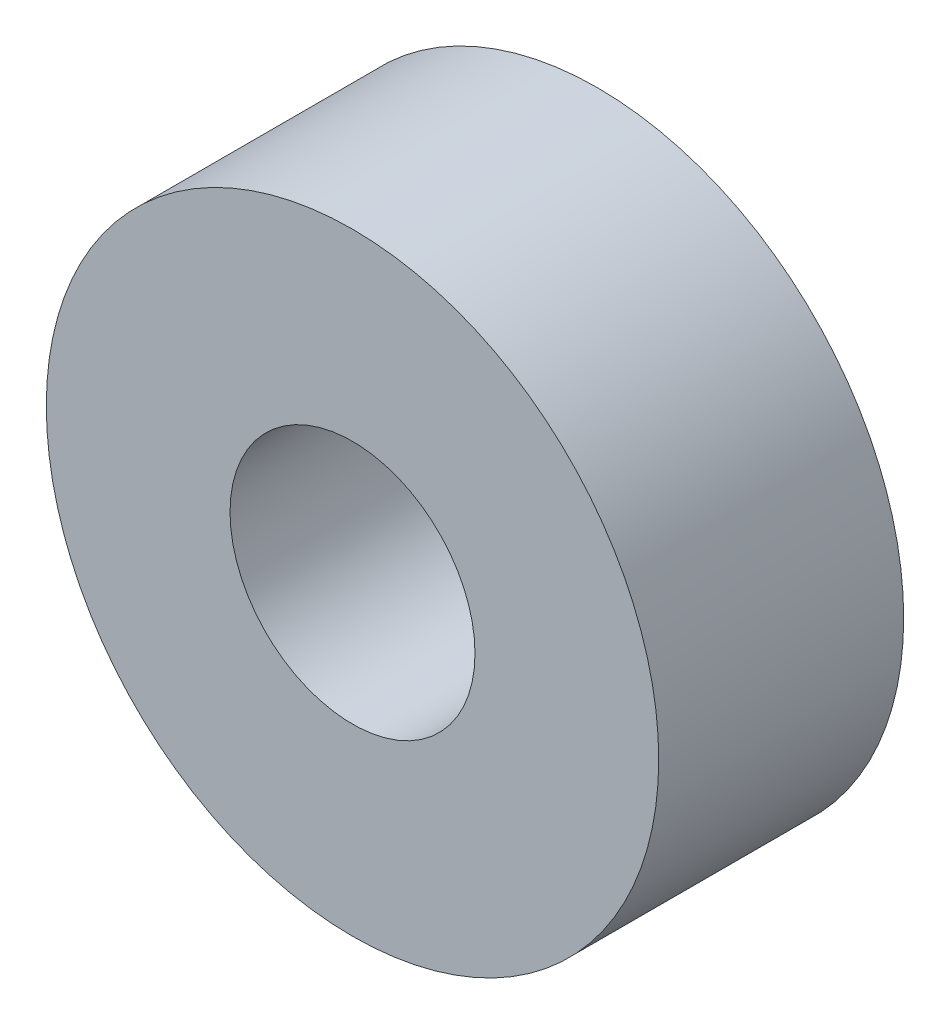
from build123d import *

# Parameters (mm, degrees)
SKETCH1_R                   = 7.9375
BOSS_EXTRUDE1_DEPTH         = 6.35
F_1_4_0_25_DIAMETER_HOLE1_D = 6.35


with BuildPart() as part:
    # Sketch1 → Boss-Extrude1 (new body)
    with BuildSketch(Plane.XY):
        Circle(SKETCH1_R)
    extrude(amount=BOSS_EXTRUDE1_DEPTH)

    # 1/4 (0.25) Diameter Hole1 (through all)
    with Locations(Plane.XY.offset(6.35)):
        with Locations((0, 0)):
            Hole(F_1_4_0_25_DIAMETER_HOLE1_D / 2)


solid = part.part
